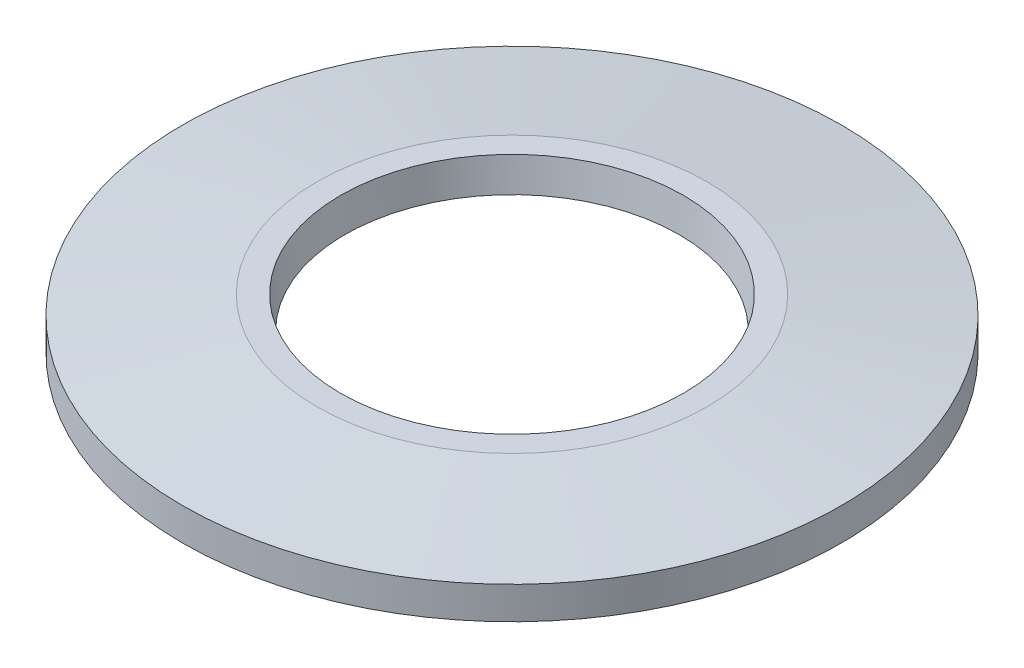
from build123d import *


with BuildPart() as part:
    # Sketch1 → Revolve1 (revolve)
    with BuildSketch(Plane(origin=(0, 0, 0), x_dir=(0, 0, -1), z_dir=(1, 0, 0))):
        Polygon((-14, -2.15), (-13, -2.15), (-7.1, -1.354035453), (-7.282671901, 0), (-8.282671901, 0), (-14, -0.771320419), align=None)
    revolve(axis=Axis((0, -9.295223809, 0), (0, 1, 0)))


solid = part.part
